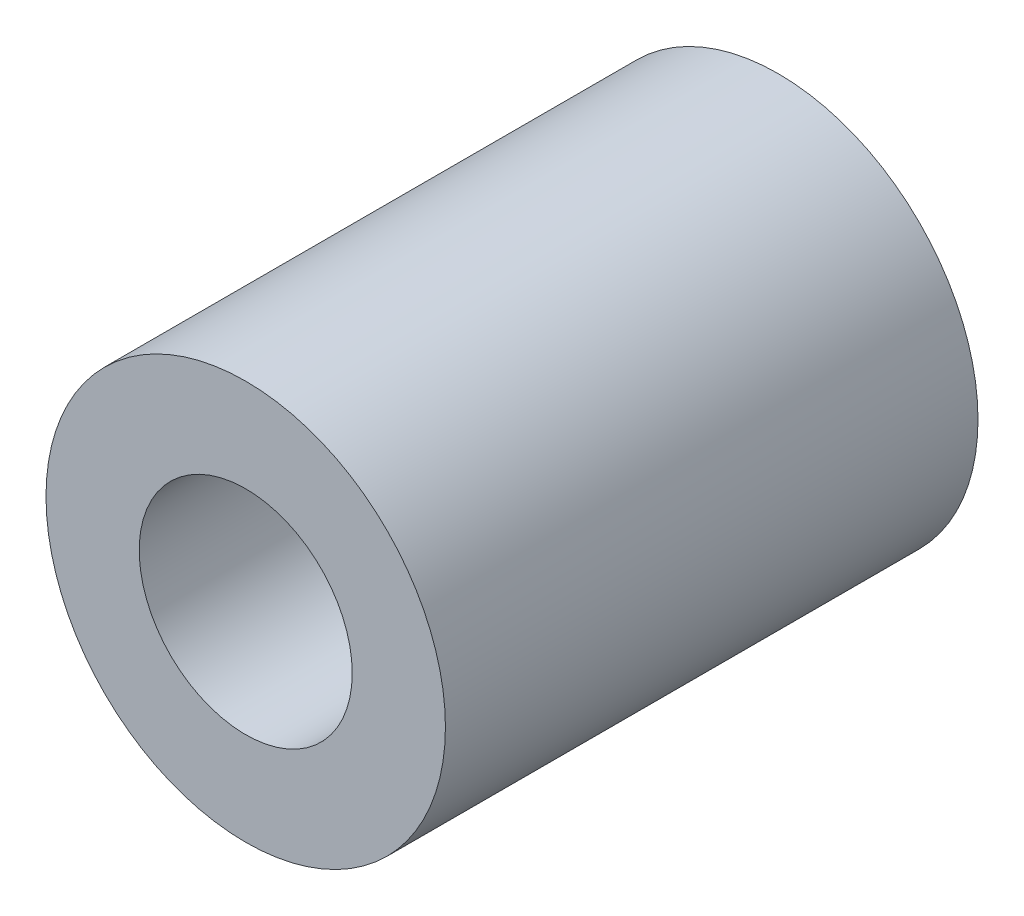
from build123d import *

# Parameters (mm, degrees)
ESQUISSE1_R      = 3
ESQUISSE1_R_2    = 1.6
EXTRUSION1_DEPTH = 8


with BuildPart() as part:
    # Esquisse1 → Extrusion1 (new body)
    with BuildSketch(Plane.XY):
        Circle(ESQUISSE1_R)
        Circle(ESQUISSE1_R_2, mode=Mode.SUBTRACT)
    extrude(amount=EXTRUSION1_DEPTH)


solid = part.part
